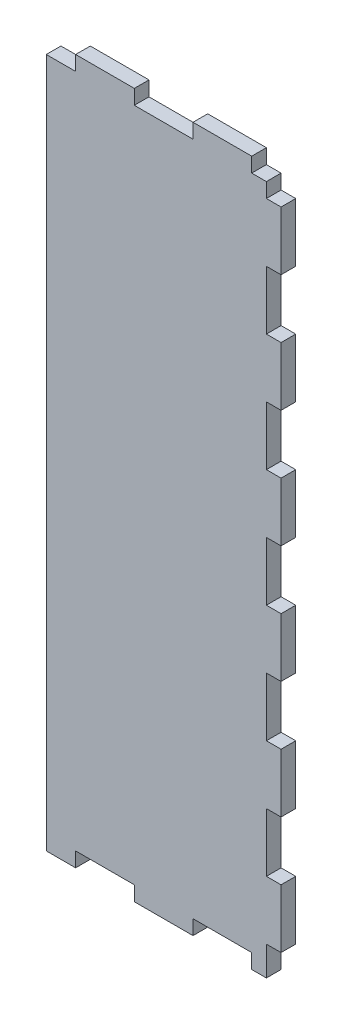
from build123d import *

# Parameters (mm, degrees)
SKETCH1_W          = 50.8
SKETCH1_H          = 152.4
EXTRUDE1_DEPTH     = 3.175
SKETCH3_W          = 3.175
SKETCH3_H          = 6.35
CUT_EXTRUDE1_DEPTH = 3.175
LPATTERN1_COUNT    = 2
LPATTERN1_PITCH    = 146.05
SKETCH4_W          = 3.175
SKETCH4_H          = 12.7
CUT_EXTRUDE2_DEPTH = 3.175
LPATTERN2_COUNT    = 5
LPATTERN2_PITCH    = 25.4
SKETCH5_W          = 12.7
SKETCH5_H          = 3.175
CUT_EXTRUDE3_DEPTH = 3.175
SKETCH6_W          = 6.35
SKETCH6_H          = 3.175
CUT_EXTRUDE4_DEPTH = 3.175
LPATTERN3_COUNT    = 2
LPATTERN3_PITCH    = 44.45
LPATTERN4_COUNT    = 2
LPATTERN4_PITCH    = 25.4
SKETCH7_W          = 12.7
SKETCH7_H          = 3.175
CUT_EXTRUDE5_DEPTH = 4.175


with BuildPart() as part:
    # Sketch1 → Extrude1 (new body)
    with BuildSketch(Plane.XY):
        with Locations((25.4, 76.2)):
            Rectangle(SKETCH1_W, SKETCH1_H)
    extrude(amount=EXTRUDE1_DEPTH)

    # Sketch3 → Cut-Extrude1 (cut)
    with BuildSketch(Plane.XY.offset(3.175)):
        with Locations((49.2125, 149.225)):
            Rectangle(SKETCH3_W, SKETCH3_H)
    cut_extrude1 = extrude(amount=-CUT_EXTRUDE1_DEPTH, mode=Mode.SUBTRACT)

    # LPattern1: Cut-Extrude1 ×2
    with Locations(*[(0, -i * LPATTERN1_PITCH, 0) for i in range(1, LPATTERN1_COUNT)]):
        add(cut_extrude1, mode=Mode.SUBTRACT)

    # Sketch4 → Cut-Extrude2 (cut)
    with BuildSketch(Plane.XY.offset(3.175)):
        with Locations((49.2125, 127)):
            Rectangle(SKETCH4_W, SKETCH4_H)
    cut_extrude2 = extrude(amount=-CUT_EXTRUDE2_DEPTH, mode=Mode.SUBTRACT)

    # LPattern2: Cut-Extrude2 ×5
    with Locations(*[(0, -i * LPATTERN2_PITCH, 0) for i in range(1, LPATTERN2_COUNT)]):
        add(cut_extrude2, mode=Mode.SUBTRACT)

    # Sketch5 → Cut-Extrude3 (cut)
    with BuildSketch(Plane.XY.offset(3.175)):
        with Locations((12.7, 1.5875)):
            Rectangle(SKETCH5_W, SKETCH5_H)
    cut_extrude3 = extrude(amount=-CUT_EXTRUDE3_DEPTH, mode=Mode.SUBTRACT)

    # Sketch6 → Cut-Extrude4 (cut)
    with BuildSketch(Plane.XY.offset(3.175)):
        with Locations((3.175, 150.8125)):
            Rectangle(SKETCH6_W, SKETCH6_H)
    cut_extrude4 = extrude(amount=-CUT_EXTRUDE4_DEPTH, mode=Mode.SUBTRACT)

    # LPattern3: Cut-Extrude4 ×2
    with Locations(*[(i * LPATTERN3_PITCH, 0, 0) for i in range(1, LPATTERN3_COUNT)]):
        add(cut_extrude4, mode=Mode.SUBTRACT)

    # LPattern4: Cut-Extrude3 ×2
    with Locations(*[(i * LPATTERN4_PITCH, 0, 0) for i in range(1, LPATTERN4_COUNT)]):
        add(cut_extrude3, mode=Mode.SUBTRACT)

    # Sketch7 → Cut-Extrude5 (cut, through all)
    with BuildSketch(Plane.XY.offset(3.175)):
        with Locations((25.4, 150.8125)):
            Rectangle(SKETCH7_W, SKETCH7_H)
    extrude(amount=-CUT_EXTRUDE5_DEPTH, mode=Mode.SUBTRACT)


solid = part.part
